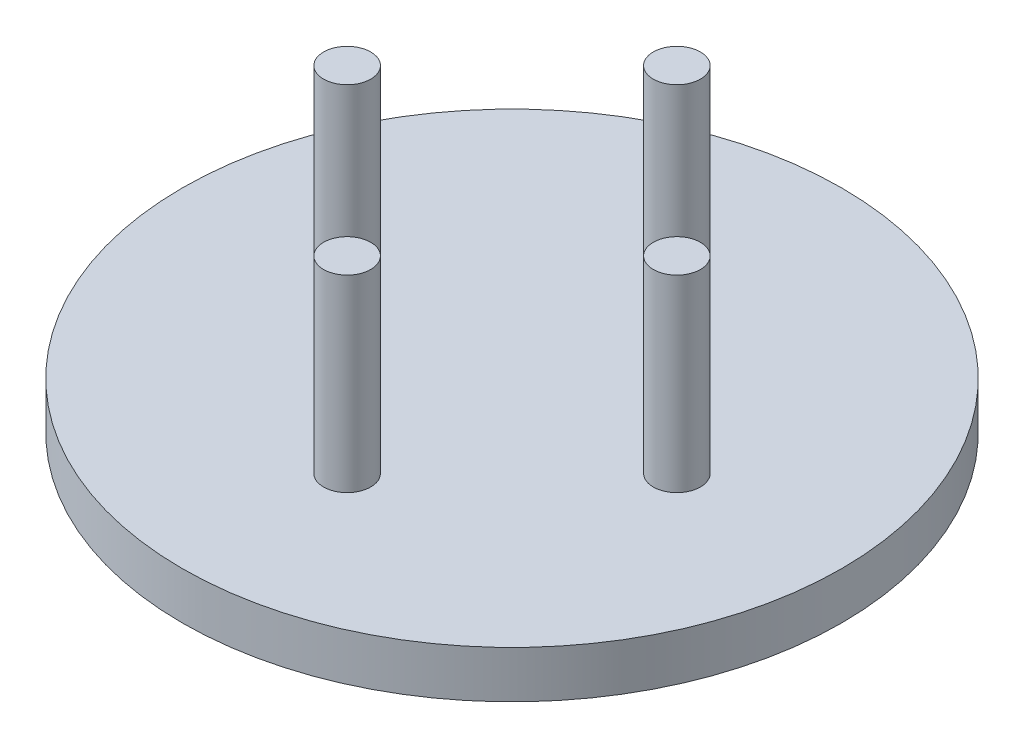
from build123d import *

# Parameters (mm, degrees)
SKETCH1_R           = 177.8
BOSS_EXTRUDE1_DEPTH = 12.7
SKETCH2_R           = 12.7
BOSS_EXTRUDE2_DEPTH = 101.6


with BuildPart() as part:
    # Sketch1 → Boss-Extrude1 (new body, symmetric)
    with BuildSketch(Plane(origin=(0, 0, 0), x_dir=(1, 0, 0), z_dir=(0, 1, 0))):
        Circle(SKETCH1_R)
    extrude(amount=BOSS_EXTRUDE1_DEPTH, both=True)

    # Sketch2 → Boss-Extrude2 (add)
    with BuildSketch(Plane(origin=(0, 12.7, 0), x_dir=(1, 0, 0), z_dir=(0, 1, 0))):
        with Locations((0, 88.9)):
            Circle(SKETCH2_R)
        with Locations((0, -88.9)):
            Circle(SKETCH2_R)
        with Locations((88.9, 0)):
            Circle(SKETCH2_R)
        with Locations((-88.9, 0)):
            Circle(SKETCH2_R)
    extrude(amount=BOSS_EXTRUDE2_DEPTH)


solid = part.part
